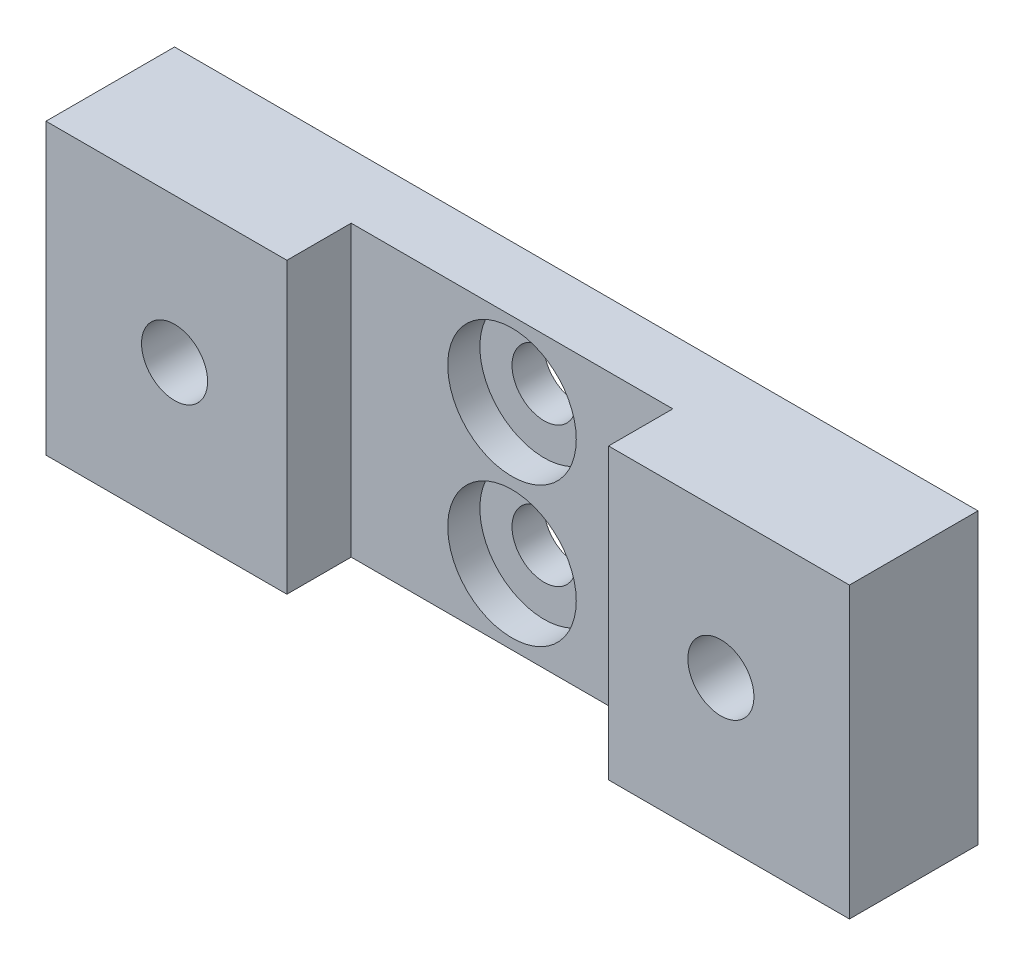
from build123d import *

# Parameters (mm, degrees)
BOSS_EXTRUDE1_DEPTH      = 28.575
HOLE1_D                  = 6.35
HOLE1_DEPTH              = 6.35
HOLE1_CBORE_D            = 12.7
HOLE1_CBORE_DEPTH        = 3.175
HOLE1_TIP                = 1.907732465
F_5_16_18_TAPPED_HOLE1_D = 6.5278


with BuildPart() as part:
    # Sketch1 → Boss-Extrude1 (new body)
    with BuildSketch(Plane(origin=(0, 0, 0), x_dir=(1, 0, 0), z_dir=(0, 1, 0))):
        Polygon((-39.6875, 0), (39.6875, 0), (39.6875, -12.7), (15.8877, -12.7), (15.8877, -6.35), (-15.8877, -6.35), (-15.8877, -12.7), (-39.6875, -12.7), align=None)
    extrude(amount=BOSS_EXTRUDE1_DEPTH)

    # Hole1
    with Locations(Plane(origin=(0, 0, 6.35), x_dir=(-1, 0, 0), z_dir=(0, 0, 1))):
        with Locations((0, -7.3787), (0, -21.1963)):
            CounterBoreHole(HOLE1_D / 2, HOLE1_CBORE_D / 2, HOLE1_CBORE_DEPTH, depth=HOLE1_DEPTH)
            with Locations((0, 0, -(HOLE1_DEPTH + HOLE1_TIP / 2))):  # 118° drill point
                Cone(0, HOLE1_D / 2, HOLE1_TIP, mode=Mode.SUBTRACT)

    # 5/16-18 Tapped Hole1 (through all)
    with Locations(Plane.XY.offset(12.7)):
        with Locations((-26.9875, 14.2875), (26.9875, 14.2875)):
            Hole(F_5_16_18_TAPPED_HOLE1_D / 2)


solid = part.part
